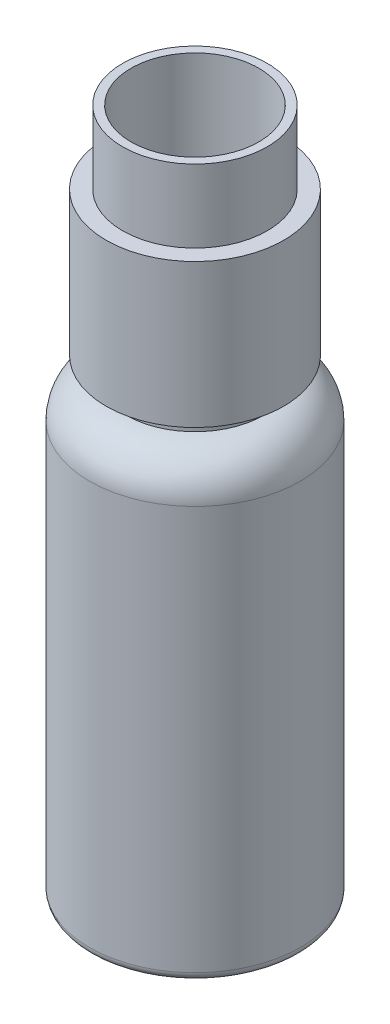
from build123d import *


with BuildPart() as part:
    # Sketch1 → Revolve1 (revolve)
    with BuildSketch(Plane.XY):
        with BuildLine():
            ThreePointArc((8.75, 1), (9.042893219, 0.292893219), (9.75, 0))
            Line((9.75, 0), (10.875, 0))
            ThreePointArc((10.875, 0), (11.582106781, 0.292893219), (11.875, 1))
            Line((11.875, 1), (11.875, 46.5))
            ThreePointArc((11.875, 46.5), (10.593592168, 49.593592168), (7.5, 50.875))
            Line((7.5, 50.875), (7.75, 50.875))
            Line((7.75, 50.875), (7.75, 52.875))
            Line((7.75, 52.875), (10, 52.875))
            Line((10, 52.875), (10, 69.075))
            Line((10, 69.075), (8.15, 69.075))
            Line((8.15, 69.075), (8.15, 77.275))
            Line((8.15, 77.275), (7.2, 77.275))
            Line((7.2, 77.275), (7.2, 63.575))
            Line((7.2, 63.575), (0, 63.575))
            Line((0, 63.575), (0, 2.409558552))
            Line((0, 2.409558552), (7.75, 2.409558552))
            ThreePointArc((7.75, 2.409558552), (8.457106781, 2.116665333), (8.75, 1.409558552))
            Line((8.75, 1.409558552), (8.75, 1))
        make_face()
    revolve(axis=Axis((0, 65.8, 0), (0, -1, 0)))


solid = part.part
